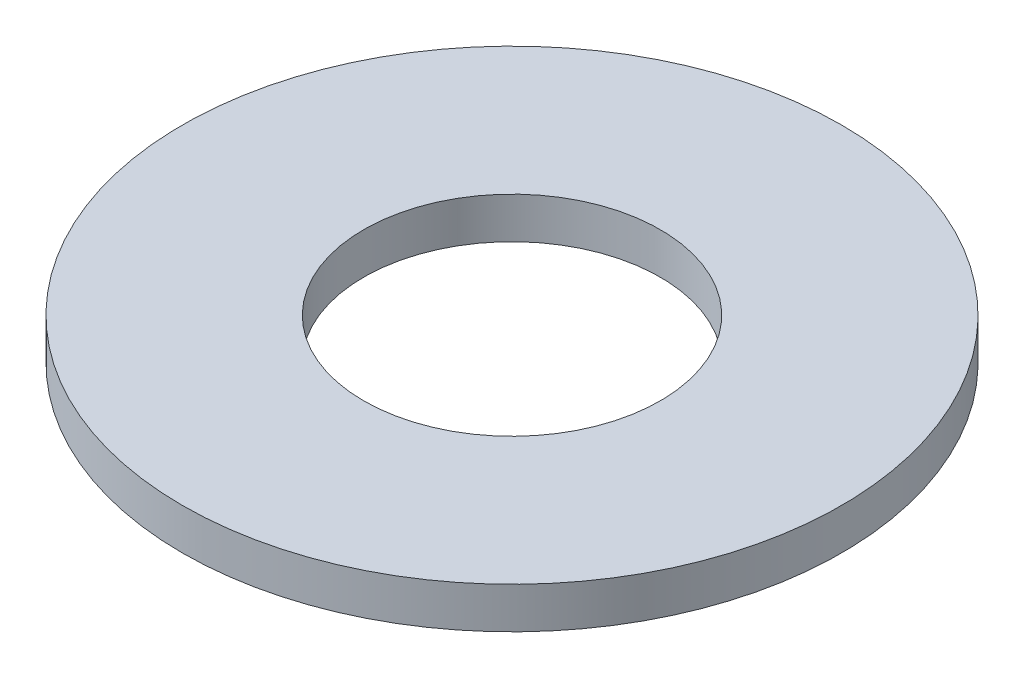
from build123d import *

# Parameters (mm, degrees)
SKETCH1_R           = 4
SKETCH1_R_2         = 1.8
BOSS_EXTRUDE1_DEPTH = 0.5


with BuildPart() as part:
    # Sketch1 → Boss-Extrude1 (new body)
    with BuildSketch(Plane(origin=(0, 0, 0), x_dir=(1, 0, 0), z_dir=(0, 1, 0))):
        Circle(SKETCH1_R)
        Circle(SKETCH1_R_2, mode=Mode.SUBTRACT)
    extrude(amount=BOSS_EXTRUDE1_DEPTH)


solid = part.part
